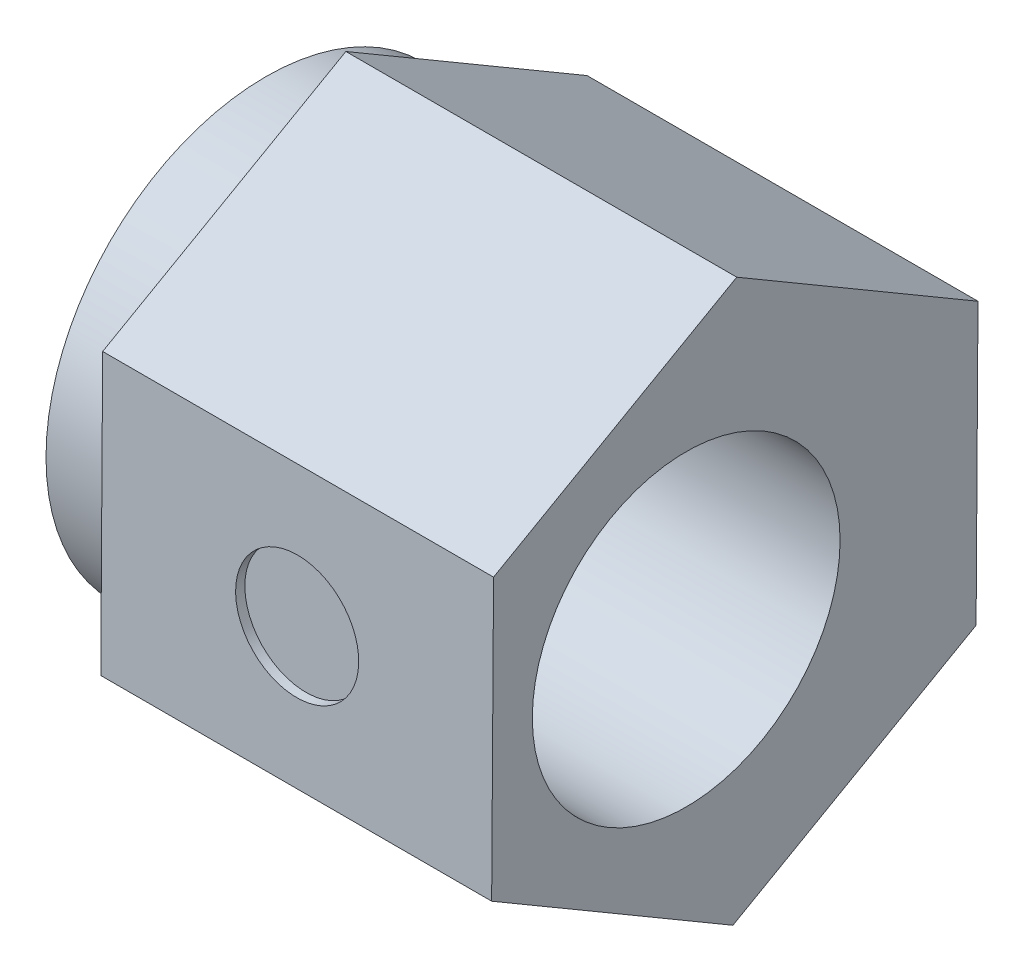
from build123d import *

# Parameters (mm, degrees)
BOSS_EXTRUDE1_DEPTH = 6.35
SKETCH4_R           = 3.57
BOSS_EXTRUDE2_DEPTH = 1.27
SKETCH3_R           = 2.5
CUT_EXTRUDE1_DEPTH  = 8.62
SKETCH5_R           = 1
CUT_EXTRUDE3_DEPTH  = 0.15


with BuildPart() as part:
    # Sketch2 → Boss-Extrude1 (new body)
    with BuildSketch(Plane(origin=(0, 0, 0), x_dir=(0, 0, -1), z_dir=(1, 0, 0))):
        Polygon((3.919437566, -2.29861752), (3.950379949, 2.245023741), (0.030942383, 4.54364126), (-3.919437566, 2.29861752), (-3.950379949, -2.245023741), (-0.030942383, -4.54364126), align=None)
    extrude(amount=BOSS_EXTRUDE1_DEPTH)

    # Sketch4 → Boss-Extrude2 (add)
    with BuildSketch(Plane.ZY):
        Circle(SKETCH4_R)
    extrude(amount=BOSS_EXTRUDE2_DEPTH)

    # Sketch3 → Cut-Extrude1 (cut, through all)
    with BuildSketch(Plane.ZY.offset(1.27)):
        with Locations((0.79, 0)):
            Circle(SKETCH3_R)
    extrude(amount=-CUT_EXTRUDE1_DEPTH, mode=Mode.SUBTRACT)

    # Sketch5 → Cut-Extrude3 (cut)
    with BuildSketch(Plane(origin=(0, 0.02679689, 3.934908757), x_dir=(1, 0, 0), z_dir=(0, -0.006809883, -0.999976812))):
        with Locations((3.175, 0)):
            Circle(SKETCH5_R)
    extrude(amount=CUT_EXTRUDE3_DEPTH, mode=Mode.SUBTRACT)


solid = part.part
